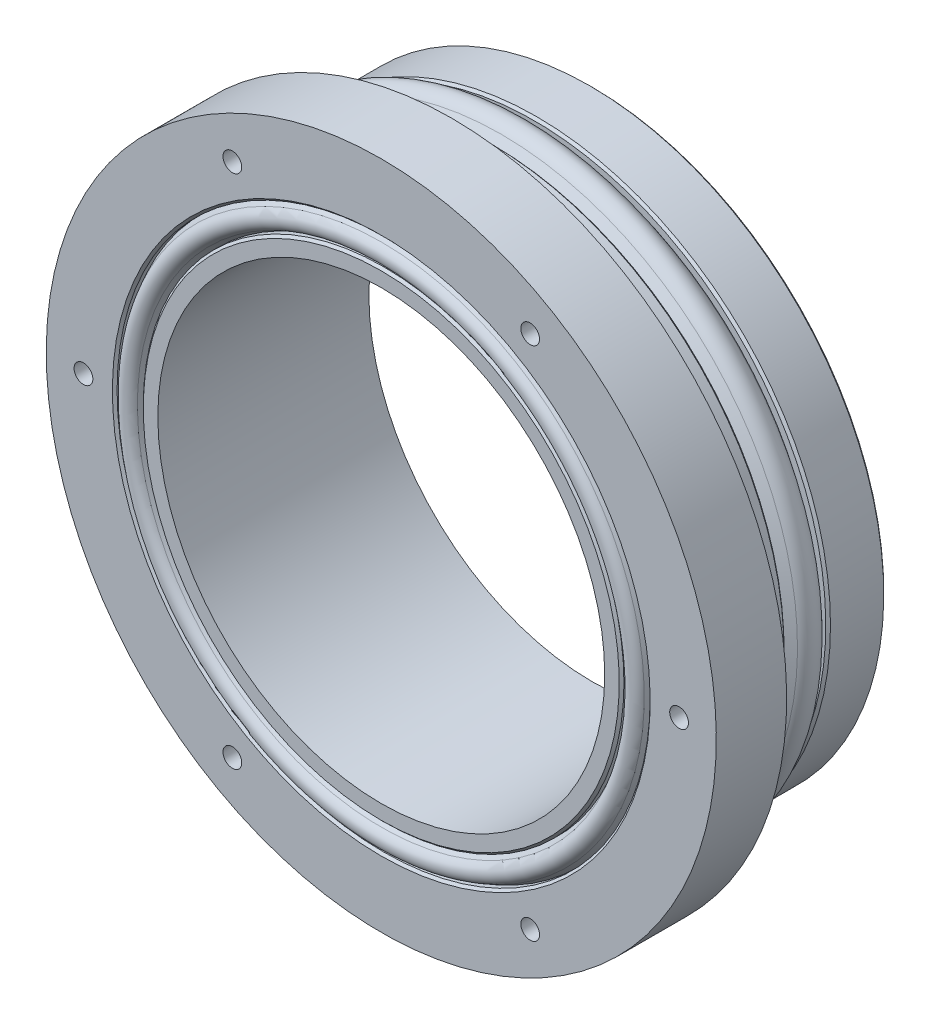
from build123d import *

# Parameters (mm, degrees)
SKETCH2_R          = 0.8
CUT_EXTRUDE1_DEPTH = 3.5
CHAMFER1_SIZE      = 0.2
SKETCH3_R          = 1.25
CUT_EXTRUDE2_DEPTH = 4


with BuildPart() as part:
    # Sketch1 → Revolve1 (revolve)
    with BuildSketch(Plane(origin=(0, 0, 0), x_dir=(0, 0, -1), z_dir=(1, 0, 0))):
        with BuildLine():
            Line((0, 25.0571), (-4.944, 25.0571))
            Line((-4.944, 25.0571), (-4.944, 24.2951))
            Line((-4.944, 24.2951), (-5.680470391, 25.264317516))
            ThreePointArc((-5.680470391, 25.264317516), (-6.722, 25.781), (-7.763529609, 25.264317516))
            Line((-7.763529609, 25.264317516), (-8.5, 24.2951))
            Line((-8.5, 24.2951), (-8.5, 25.0571))
            Line((-8.5, 25.0571), (-12, 25.0571))
            Line((-12, 25.0571), (-12, 28.575))
            Line((-12, 28.575), (-18, 28.575))
            Line((-18, 28.575), (-18, 22.733))
            Line((-18, 22.733), (-17.3396, 22.733))
            Line((-17.3396, 22.733), (-17.975134466, 22.405795686))
            ThreePointArc((-17.975134466, 22.405795686), (-18.4572, 21.6154), (-17.975134466, 20.825004314))
            Line((-17.975134466, 20.825004314), (-17.3396, 20.4978))
            Line((-17.3396, 20.4978), (-18, 20.4978))
            Line((-18, 20.4978), (-18, 19.0571))
            Line((-18, 19.0571), (0, 19.0571))
            Line((0, 19.0571), (0, 25.0571))
        make_face()
    revolve(axis=Axis((0, 0, 0), (0, 0, 1)))

    # Sketch2 → Cut-Extrude1 (cut)
    with BuildSketch(Plane.XY.offset(18)):
        with Locations((-25.4, 0)):
            Circle(SKETCH2_R)
        with Locations((-12.7, 21.997045256)):
            Circle(SKETCH2_R)
        with Locations((12.7, 21.997045256)):
            Circle(SKETCH2_R)
        with Locations((25.4, 0)):
            Circle(SKETCH2_R)
        with Locations((12.7, -21.997045256)):
            Circle(SKETCH2_R)
        with Locations((-12.7, -21.997045256)):
            Circle(SKETCH2_R)
    extrude(amount=-CUT_EXTRUDE1_DEPTH, mode=Mode.SUBTRACT)

    # Chamfer1
    chamfer1_edges = [part.edges().sort_by_distance(p)[0] for p in [
        (0, -20.4978, 18),
        (0, -22.733, 18),
        (0, -25.0571, 8.5),
        (0, -25.0571, 4.944),
        (0, -25.0571, 0),
    ]]
    chamfer(chamfer1_edges, length=CHAMFER1_SIZE)

    # Sketch3 → Cut-Extrude2 (cut)
    with BuildSketch(Plane(origin=(0, 0, 0), x_dir=(-1, 0, 0), z_dir=(0, 0, -1))):
        with Locations((0, 21.5)):
            Circle(SKETCH3_R)
        with Locations((21.5, 0)):
            Circle(SKETCH3_R)
        with Locations((0, -21.5)):
            Circle(SKETCH3_R)
        with Locations((-21.5, 0)):
            Circle(SKETCH3_R)
    extrude(amount=-CUT_EXTRUDE2_DEPTH, mode=Mode.SUBTRACT)


solid = part.part
